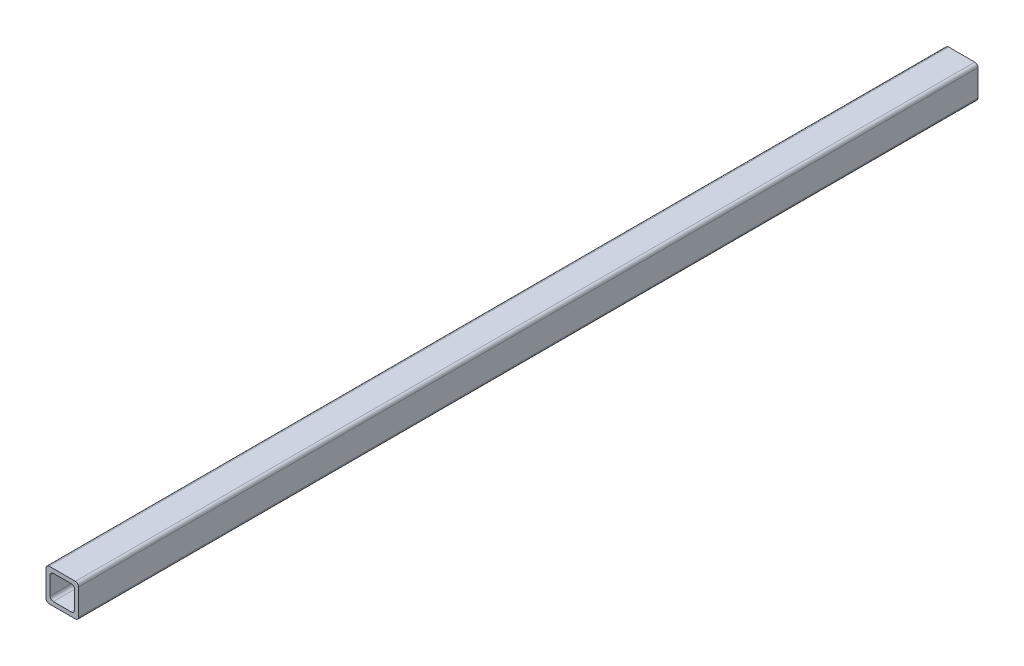
from build123d import *

# Parameters (mm, degrees)
SALIENTE_EXTRUIR1_DEPTH = 700


with BuildPart() as part:
    # Croquis1 → Saliente-Extruir1 (new body)
    with BuildSketch(Plane.XY):
        with BuildLine():
            Line((-10.2, -12.7), (10.2, -12.7))
            ThreePointArc((10.2, -12.7), (11.967766953, -11.967766953), (12.7, -10.2))
            Line((12.7, -10.2), (12.7, 10.2))
            ThreePointArc((12.7, 10.2), (11.967766953, 11.967766953), (10.2, 12.7))
            Line((10.2, 12.7), (-10.2, 12.7))
            ThreePointArc((-10.2, 12.7), (-11.967766953, 11.967766953), (-12.7, 10.2))
            Line((-12.7, 10.2), (-12.7, -10.2))
            ThreePointArc((-12.7, -10.2), (-11.967766953, -11.967766953), (-10.2, -12.7))
        make_face()
        with BuildLine():
            Line((-7.025, -9.525), (7.025, -9.525))
            ThreePointArc((7.025, -9.525), (8.792766953, -8.792766953), (9.525, -7.025))
            Line((9.525, -7.025), (9.525, 7.025))
            ThreePointArc((9.525, 7.025), (8.792766953, 8.792766953), (7.025, 9.525))
            Line((7.025, 9.525), (-7.025, 9.525))
            ThreePointArc((-7.025, 9.525), (-8.792766953, 8.792766953), (-9.525, 7.025))
            Line((-9.525, 7.025), (-9.525, -7.025))
            ThreePointArc((-9.525, -7.025), (-8.792766953, -8.792766953), (-7.025, -9.525))
        make_face(mode=Mode.SUBTRACT)
    extrude(amount=SALIENTE_EXTRUIR1_DEPTH)


solid = part.part
